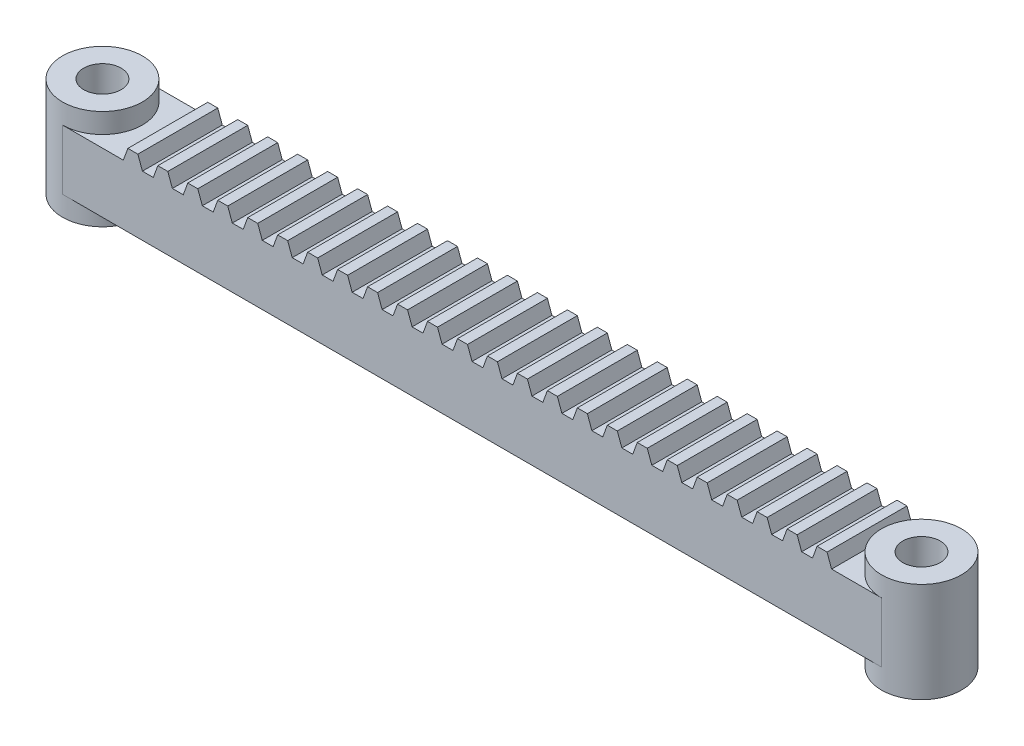
from build123d import *

# Parameters (mm, degrees)
SKETCH1_W                = 164
SKETCH1_H                = 16
BOSS_EXTRUDE1_DEPTH      = 12
SKETCH2_R                = 8
BOSS_EXTRUDE2_DEPTH      = 4
BOSS_EXTRUDE2_DEPTH_BACK = 16
BOSS_EXTRUDE3_DEPTH      = 16
LPATTERN1_COUNT          = 24
LPATTERN1_PITCH          = 6
SKETCH4_R                = 3.75
CUT_EXTRUDE1_DEPTH       = 5
CUT_EXTRUDE1_DEPTH_BACK  = 17


with BuildPart() as part:
    # Sketch1 → Boss-Extrude1 (new body)
    with BuildSketch(Plane(origin=(0, 0, 0), x_dir=(1, 0, 0), z_dir=(0, 1, 0))):
        Rectangle(SKETCH1_W, SKETCH1_H)
    extrude(amount=BOSS_EXTRUDE1_DEPTH)

    # Sketch2 → Boss-Extrude2 (add, two sides)
    with BuildSketch(Plane(origin=(0, 12, 0), x_dir=(1, 0, 0), z_dir=(0, 1, 0))) as boss_extrude2_sk:
        with Locations((-82, 0)):
            Circle(SKETCH2_R)
        with Locations((82, 0)):
            Circle(SKETCH2_R)
    extrude(amount=BOSS_EXTRUDE2_DEPTH)
    extrude(boss_extrude2_sk.sketch, amount=-BOSS_EXTRUDE2_DEPTH_BACK)

    # Sketch3 → Boss-Extrude3 (add)
    with BuildSketch(Plane.XY.offset(8)):
        Polygon((68.180148829, 12), (72, 12), (71.090074414, 14.5), (69.090074414, 14.5), align=None)
    boss_extrude3 = extrude(amount=-BOSS_EXTRUDE3_DEPTH)

    # LPattern1: Boss-Extrude3 ×24
    with Locations(*[(-i * LPATTERN1_PITCH, 0, 0) for i in range(1, LPATTERN1_COUNT)]):
        add(boss_extrude3)

    # Sketch4 → Cut-Extrude1 (cut, two sides)
    with BuildSketch(Plane.XZ) as cut_extrude1_sk:
        with Locations((-82, 0)):
            Circle(SKETCH4_R)
        with Locations((82, 0)):
            Circle(SKETCH4_R)
    extrude(amount=CUT_EXTRUDE1_DEPTH, mode=Mode.SUBTRACT)
    extrude(cut_extrude1_sk.sketch, amount=-CUT_EXTRUDE1_DEPTH_BACK, mode=Mode.SUBTRACT)


solid = part.part
